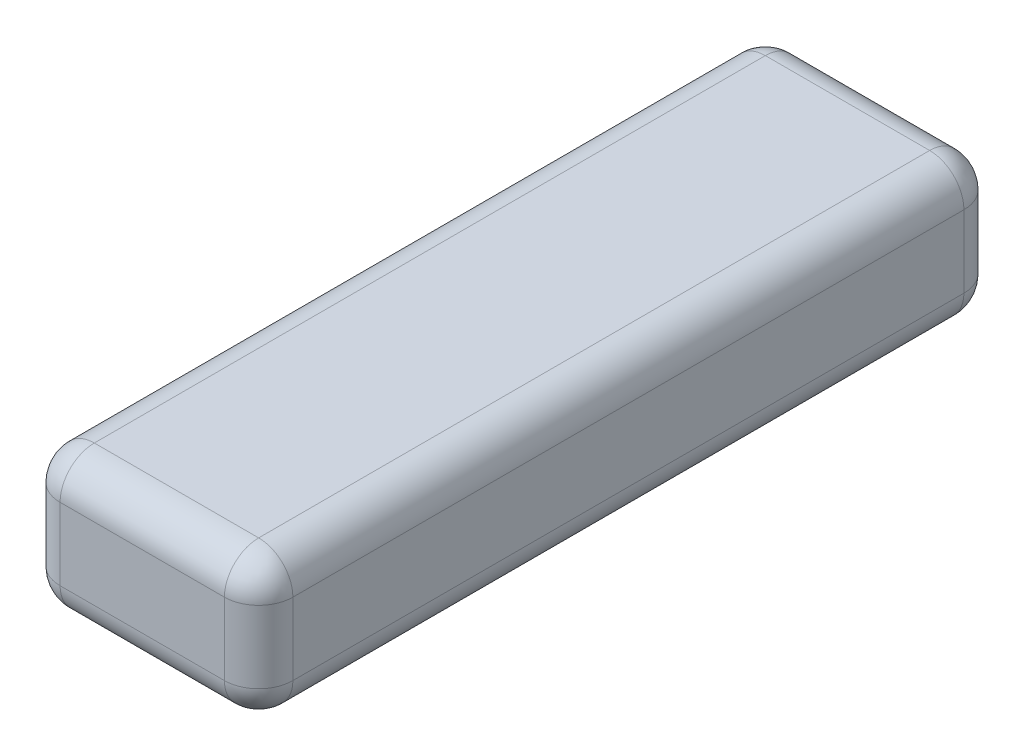
from build123d import *

# Parameters (mm, degrees)
ESQUISSE1_W             = 34
ESQUISSE1_H             = 108
BOSS_EXTRU_1_DEPTH      = 10.5
BOSS_EXTRU_1_DEPTH_BACK = 10.05
CONG_1_R                = 5
CONG_2_R                = 5


with BuildPart() as part:
    # Esquisse1 → Boss.-Extru.1 (new body, two sides)
    with BuildSketch(Plane(origin=(0, 0, 0), x_dir=(1, 0, 0), z_dir=(0, 1, 0))) as boss_extru_1_sk:
        Rectangle(ESQUISSE1_W, ESQUISSE1_H)
    extrude(amount=BOSS_EXTRU_1_DEPTH)
    extrude(boss_extru_1_sk.sketch, amount=-BOSS_EXTRU_1_DEPTH_BACK)

    # Congé1
    cong_1_edges = [part.edges().sort_by_distance(p)[0] for p in [
        (17, 0.225, 54),
        (-17, 0.225, 54),
        (-17, 0.225, -54),
        (17, 0.225, -54),
    ]]
    fillet(cong_1_edges, radius=CONG_1_R)

    # Congé2
    cong_2_edges = [part.edges().sort_by_distance(p)[0] for p in [
        (17, 10.5, 0),
        (17, -10.05, 0),
        (0, 10.5, -54),
        (-17, 10.5, 0),
        (0, 10.5, 54),
        (15.535533906, 10.5, 52.535533906),
        (-15.535533906, 10.5, 52.535533906),
        (-15.535533906, 10.5, -52.535533906),
        (15.535533906, 10.5, -52.535533906),
        (0, -10.05, -54),
        (0, -10.05, 54),
        (-17, -10.05, 0),
        (15.535533906, -10.05, 52.535533906),
        (-15.535533906, -10.05, 52.535533906),
        (-15.535533906, -10.05, -52.535533906),
        (15.535533906, -10.05, -52.535533906),
    ]]
    fillet(cong_2_edges, radius=CONG_2_R)


solid = part.part
